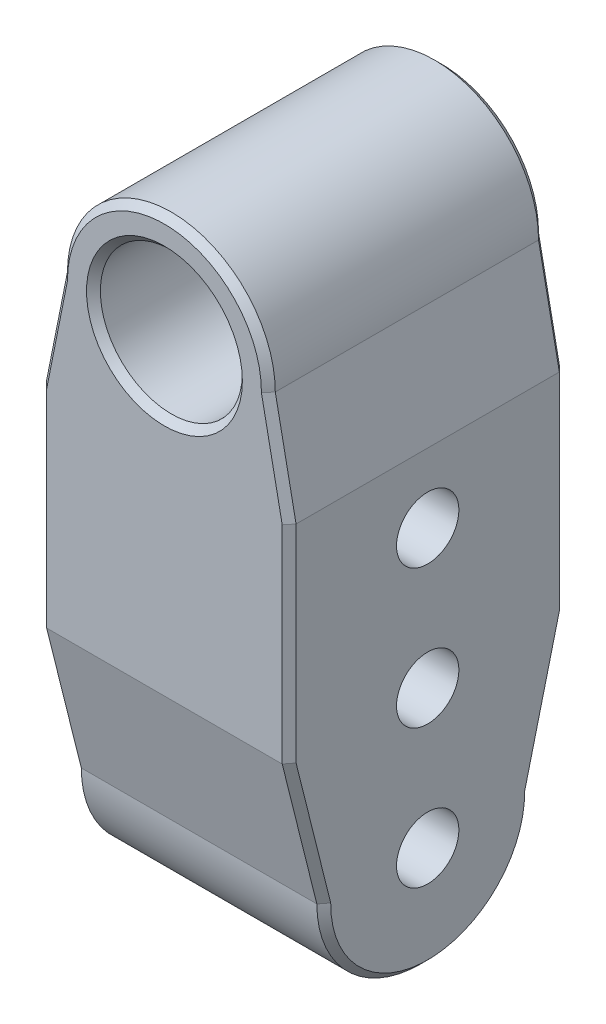
from build123d import *

# Parameters (mm, degrees)
SKETCH_1_R               = 10.25
EXTRUDE_1_DEPTH          = 20
SKETCH_2_R               = 4.5
CUT_EXTRUDE_1_DEPTH      = 20
CUT_EXTRUDE_2_DEPTH      = 1
CUT_EXTRUDE_2_DEPTH_BACK = 37
CHAMFER_1_SIZE           = 1


with BuildPart() as part:
    # 草图1 → 凸台-拉伸1 (new body, symmetric)
    with BuildSketch(Plane.XY):
        with BuildLine():
            Line((0, -80), (18, -80))
            Line((18, -80), (18, -15))
            Line((18, -15), (15, 0))
            ThreePointArc((15, 0), (0, 15), (-15, 0))
            Line((-15, 0), (-18, -15))
            Line((-18, -15), (-18, -80))
            Line((-18, -80), (0, -80))
        make_face()
        Circle(SKETCH_1_R, mode=Mode.SUBTRACT)
    extrude(amount=EXTRUDE_1_DEPTH, both=True)

    # 草图2 → 切除-拉伸1 (cut, symmetric)
    with BuildSketch(Plane(origin=(0, 0, 0), x_dir=(0, 0, -1), z_dir=(1, 0, 0))):
        with Locations((0, -45)):
            Circle(SKETCH_2_R)
        with Locations((0, -25)):
            Circle(SKETCH_2_R)
        with Locations((0, -65)):
            Circle(SKETCH_2_R)
    extrude(amount=CUT_EXTRUDE_1_DEPTH, both=True, mode=Mode.SUBTRACT)

    # 草图7 → 切除-拉伸2 (cut, two sides)
    with BuildSketch(Plane(origin=(18, 0, 0), x_dir=(0, 0, -1), z_dir=(1, 0, 0))) as cut_extrude_2_sk:
        with BuildLine():
            Line((-15, -65), (-20, -45))
            Line((-20, -45), (-20, -80))
            Line((-20, -80), (1.38e-07, -80))
            ThreePointArc((1.38e-07, -80), (-10.606601669, -75.606601767), (-15, -65))
        make_face()
        with BuildLine():
            ThreePointArc((15, -65), (10.606601767, -75.606601669), (1.38e-07, -80))
            Line((1.38e-07, -80), (20, -80))
            Line((20, -80), (20, -45))
            Line((20, -45), (15, -65))
        make_face()
    extrude(amount=CUT_EXTRUDE_2_DEPTH, mode=Mode.SUBTRACT)
    extrude(cut_extrude_2_sk.sketch, amount=-CUT_EXTRUDE_2_DEPTH_BACK, mode=Mode.SUBTRACT)

    # 倒角1
    chamfer_1_edges = [part.edges().sort_by_distance(p)[0] for p in [
        (16.5, -7.5, 20),
        (-10.25, 0, -20),
        (-10.25, 0, 20),
        (0, 15, 20),
        (-16.5, -7.5, 20),
        (-18, -30, 20),
        (-18, -55, -17.5),
        (-18, -80, 0),
        (-18, -55, 17.5),
        (18, -30, -20),
        (18, -30, 20),
        (18, -55, 17.5),
        (18, -80, 0),
        (18, -55, -17.5),
        (-18, -30, -20),
        (-16.5, -7.5, -20),
        (0, 15, -20),
        (16.5, -7.5, -20),
    ]]
    chamfer(chamfer_1_edges, length=CHAMFER_1_SIZE)


solid = part.part
